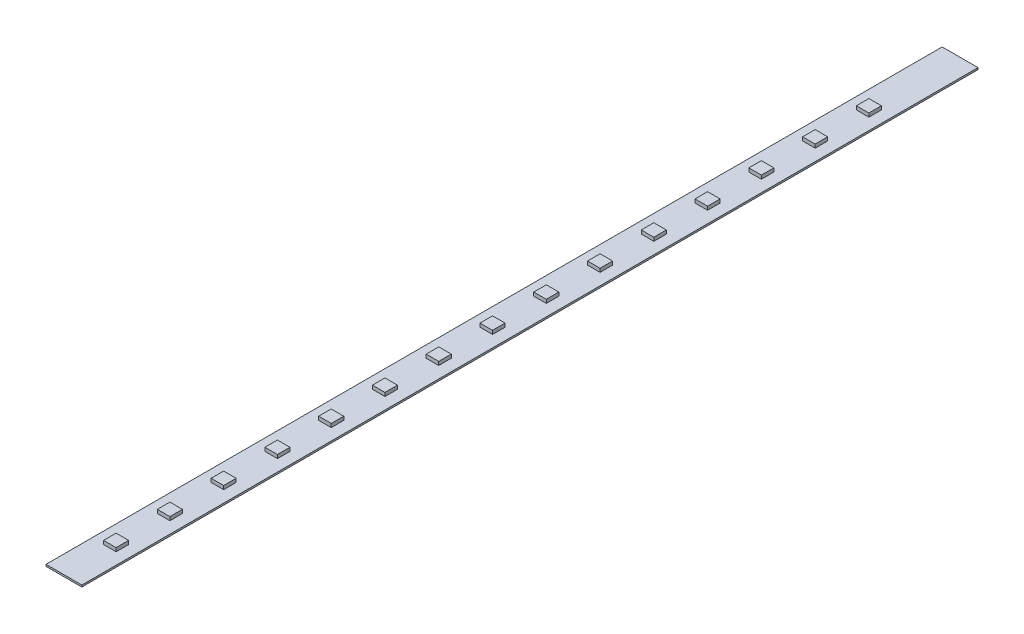
from build123d import *

# Parameters (mm, degrees)
ESQUISSE1_W                    = 20
ESQUISSE1_H                    = 500
BOSS_EXTRU_1_DEPTH             = 1
ESQUISSE2_W                    = 7
ESQUISSE2_H                    = 7
BOSS_EXTRU_2_DEPTH             = 2
R_P_TITION_LIN_AIRE1_COUNT     = 7
R_P_TITION_LIN_AIRE1_PITCH     = 30
R_P_TITION_LIN_AIRE1_COL_COUNT = 9
R_P_TITION_LIN_AIRE1_COL_PITCH = 30


with BuildPart() as part:
    # Esquisse1 → Boss.-Extru.1 (new body)
    with BuildSketch(Plane(origin=(0, 0, 0), x_dir=(1, 0, 0), z_dir=(0, 1, 0))):
        Rectangle(ESQUISSE1_W, ESQUISSE1_H)
    extrude(amount=BOSS_EXTRU_1_DEPTH)

    # Esquisse2 → Boss.-Extru.2 (add)
    with BuildSketch(Plane(origin=(0, 1, 0), x_dir=(1, 0, 0), z_dir=(0, 1, 0))):
        with Locations((0, 19.127958594)):
            Rectangle(ESQUISSE2_W, ESQUISSE2_H)
    boss_extru_2 = extrude(amount=BOSS_EXTRU_2_DEPTH)

    # Répétition linéaire1: Boss.-Extru.2 ×7
    with Locations(*[(0, 0, -i * R_P_TITION_LIN_AIRE1_PITCH) for i in range(1, R_P_TITION_LIN_AIRE1_COUNT)]):
        add(boss_extru_2)

    # Répétition linéaire1 col: Boss.-Extru.2 ×9
    with Locations(*[(0, 0, i * R_P_TITION_LIN_AIRE1_COL_PITCH) for i in range(1, R_P_TITION_LIN_AIRE1_COL_COUNT)]):
        add(boss_extru_2)


solid = part.part
